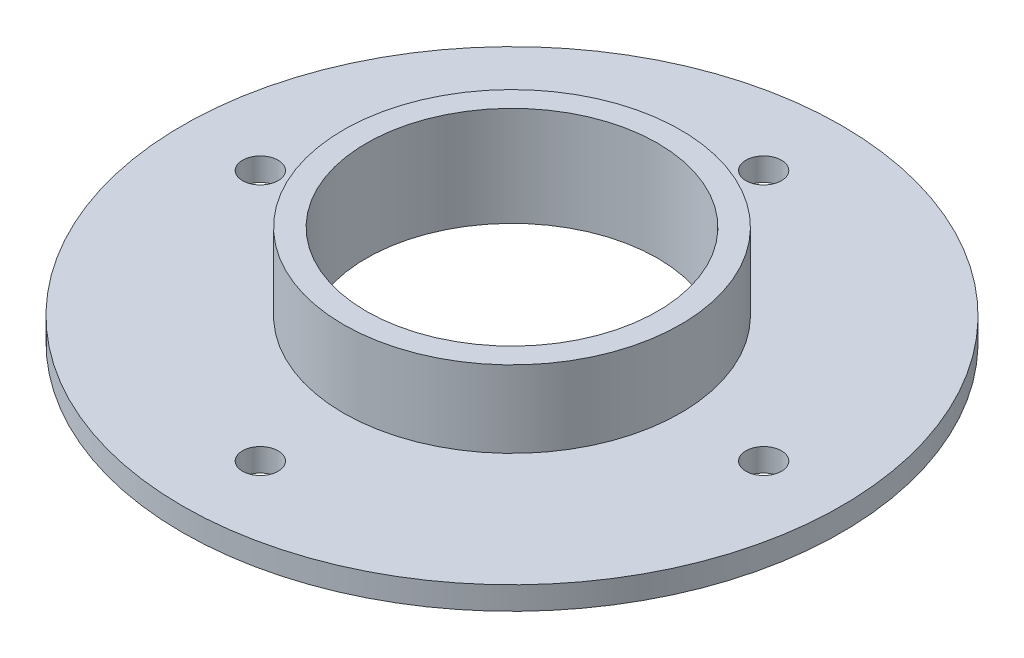
from build123d import *

# Parameters (mm, degrees)
SKETCH_1_R          = 43
EXTRUDE_1_DEPTH     = 3
SKETCH_2_R          = 22
SKETCH_2_R_2        = 19
EXTRUDE_2_DEPTH     = 10
SKETCH_3_R          = 19
SKETCH_3_R_2        = 2.320189094
CUT_EXTRUDE_1_DEPTH = 20


with BuildPart() as part:
    # 草图1 → 凸台-拉伸1 (new body)
    with BuildSketch(Plane(origin=(0, 0, 0), x_dir=(1, 0, 0), z_dir=(0, 1, 0))):
        Circle(SKETCH_1_R)
    extrude(amount=EXTRUDE_1_DEPTH)

    # 草图2 → 凸台-拉伸2 (add)
    with BuildSketch(Plane(origin=(0, 3, 0), x_dir=(1, 0, 0), z_dir=(0, 1, 0))):
        Circle(SKETCH_2_R)
        Circle(SKETCH_2_R_2, mode=Mode.SUBTRACT)
    extrude(amount=EXTRUDE_2_DEPTH)

    # 草图3 → 切除-拉伸1 (cut)
    with BuildSketch(Plane(origin=(0, 3, 0), x_dir=(1, 0, 0), z_dir=(0, 1, 0))):
        Circle(SKETCH_3_R)
        with Locations((0, 32.837689205)):
            Circle(SKETCH_3_R_2)
        with Locations((32.837689205, 0)):
            Circle(SKETCH_3_R_2)
        with Locations((0, -32.837689205)):
            Circle(SKETCH_3_R_2)
        with Locations((-32.837689205, 0)):
            Circle(SKETCH_3_R_2)
    extrude(amount=-CUT_EXTRUDE_1_DEPTH, mode=Mode.SUBTRACT)


solid = part.part
